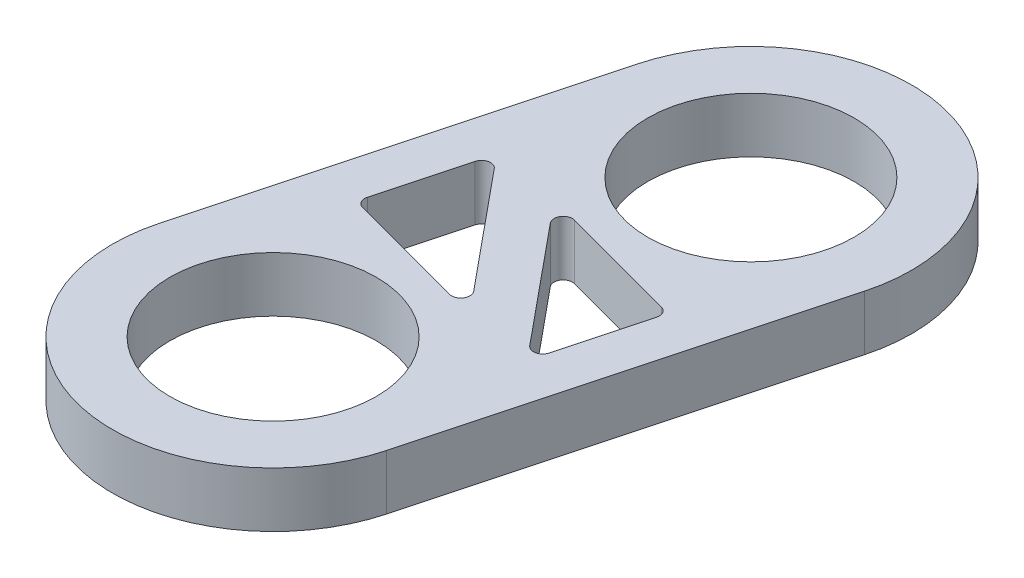
from build123d import *

# Parameters (mm, degrees)
SKETCH1_R           = 14.2875
BOSS_EXTRUDE1_DEPTH = 7.62
CUT_EXTRUDE1_DEPTH  = 8.62
FILLET1_R           = 1.27


with BuildPart() as part:
    # Sketch1 → Boss-Extrude1 (new body)
    with BuildSketch(Plane(origin=(0, 0, 0), x_dir=(1, 0, 0), z_dir=(0, 1, 0))):
        with BuildLine():
            Line((7.49794353, -57.888099751), (21.467701489, -5.752253277))
            ThreePointArc((21.467701489, -5.752253277), (17.632277988, 13.52972276), (0, 22.225))
            ThreePointArc((0, 22.225), (-13.52972276, 17.632277988), (-21.467701489, 5.752253277))
            Line((-21.467701489, 5.752253277), (-35.437459449, -46.383593197))
            ThreePointArc((-35.437459449, -46.383593197), (-19.722011237, -73.603547963), (7.49794353, -57.888099751))
        make_face()
        with Locations((-13.969757959, -52.135846474)):
            Circle(SKETCH1_R, mode=Mode.SUBTRACT)
        Circle(SKETCH1_R, mode=Mode.SUBTRACT)
    extrude(amount=BOSS_EXTRUDE1_DEPTH)

    # Sketch2 → Cut-Extrude1 (cut, through all)
    with BuildSketch(Plane(origin=(0, 7.62, 0), x_dir=(1, 0, 0), z_dir=(0, 1, 0))):
        Polygon((-20.393980488, -14.77508138), (-3.03503134, -35.86140715), (-24.502732829, -30.109153872), align=None)
        Polygon((-10.93472662, -16.274439324), (10.532974869, -22.026692602), (6.424222528, -37.360765094), align=None)
    extrude(amount=-CUT_EXTRUDE1_DEPTH, mode=Mode.SUBTRACT)

    # Fillet1
    fillet1_edges = [part.edges().sort_by_distance(p)[0] for p in [
        (-24.502732829, 3.81, 30.109153872),
        (-20.393980488, 3.81, 14.77508138),
        (-3.03503134, 3.81, 35.86140715),
        (6.424222528, 3.81, 37.360765094),
        (-10.93472662, 3.81, 16.274439324),
        (10.532974869, 3.81, 22.026692602),
    ]]
    fillet(fillet1_edges, radius=FILLET1_R)


solid = part.part
